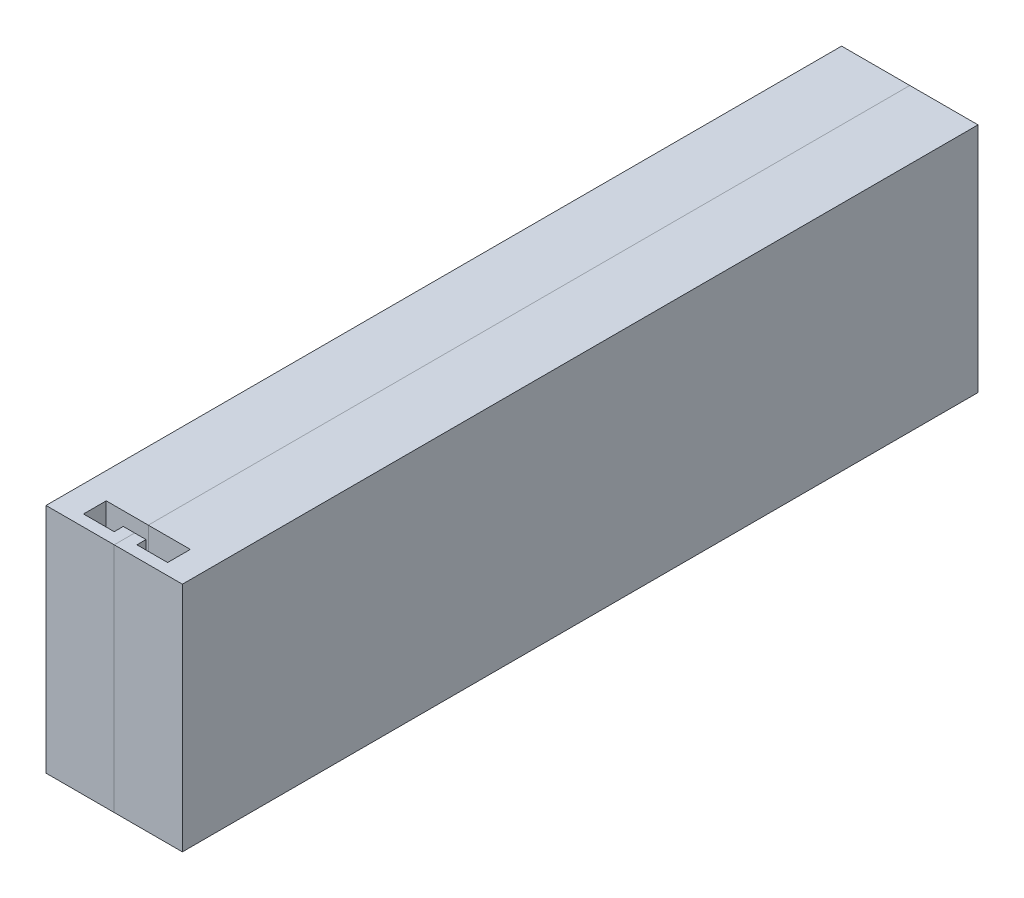
from build123d import *

# Parameters (mm, degrees)
SKETCH1_W           = 175
SKETCH1_H           = 51
BOSS_EXTRUDE1_DEPTH = 15
CUT_EXTRUDE3_DEPTH  = 52
SKETCH7_W           = 4.75
SKETCH7_H           = 4.75
CUT_EXTRUDE5_DEPTH  = 145
SKETCH10_W          = 10.05
SKETCH10_H          = 24
CUT_EXTRUDE6_DEPTH  = 16
SKETCH11_W          = 10.05
SKETCH11_H          = 8.05
CUT_EXTRUDE7_DEPTH  = 8


with BuildPart() as part:
    # Sketch1 → Boss-Extrude1 (new body)
    with BuildSketch(Plane(origin=(0, 0, 0), x_dir=(0, 0, -1), z_dir=(1, 0, 0))):
        with Locations((22.937921078, 5.057266603)):
            Rectangle(SKETCH1_W, SKETCH1_H)
    extrude(amount=BOSS_EXTRUDE1_DEPTH)

    # Sketch6 → Cut-Extrude3 (cut, through all)
    with BuildSketch(Plane(origin=(0, 30.557266603, 0), x_dir=(1, 0, 0), z_dir=(0, 1, 0))):
        Polygon((12.5, -60.062078922), (15, -60.062078922), (15, -57.062078922), (12.5, -57.062078922), (5.75, -57.062078922), (5.75, -62.062078922), (12.5, -62.062078922), align=None)
    extrude(amount=-CUT_EXTRUDE3_DEPTH, mode=Mode.SUBTRACT)

    # Sketch7 → Cut-Extrude5 (cut)
    with BuildSketch(Plane(origin=(0, 0, -110.437921078), x_dir=(-1, 0, 0), z_dir=(0, 0, -1))):
        with Locations((-12.625, 0.432266603)):
            Rectangle(SKETCH7_W, SKETCH7_H)
        with Locations((-12.625, 18.432266603)):
            Rectangle(SKETCH7_W, SKETCH7_H)
    extrude(amount=-CUT_EXTRUDE5_DEPTH, mode=Mode.SUBTRACT)

    # Sketch10 → Cut-Extrude6 (cut)
    with BuildSketch(Plane(origin=(0, 0, -110.437921078), x_dir=(-1, 0, 0), z_dir=(0, 0, -1))):
        with Locations((-9.975, 9.557266603)):
            Rectangle(SKETCH10_W, SKETCH10_H)
    extrude(amount=-CUT_EXTRUDE6_DEPTH, mode=Mode.SUBTRACT)

    # Sketch11 → Cut-Extrude7 (cut)
    with BuildSketch(Plane(origin=(0, -2.442733397, 0), x_dir=(1, 0, 0), z_dir=(0, 1, 0))):
        with Locations((9.975, 98.462921078)):
            Rectangle(SKETCH11_W, SKETCH11_H)
    extrude(amount=-CUT_EXTRUDE7_DEPTH, mode=Mode.SUBTRACT)


with BuildPart() as body_2:
    # Mirror4: mirrored copy
    add(part.part.mirror(Plane.ZY.offset(-15)))


solid = Compound([part.part, body_2.part])
